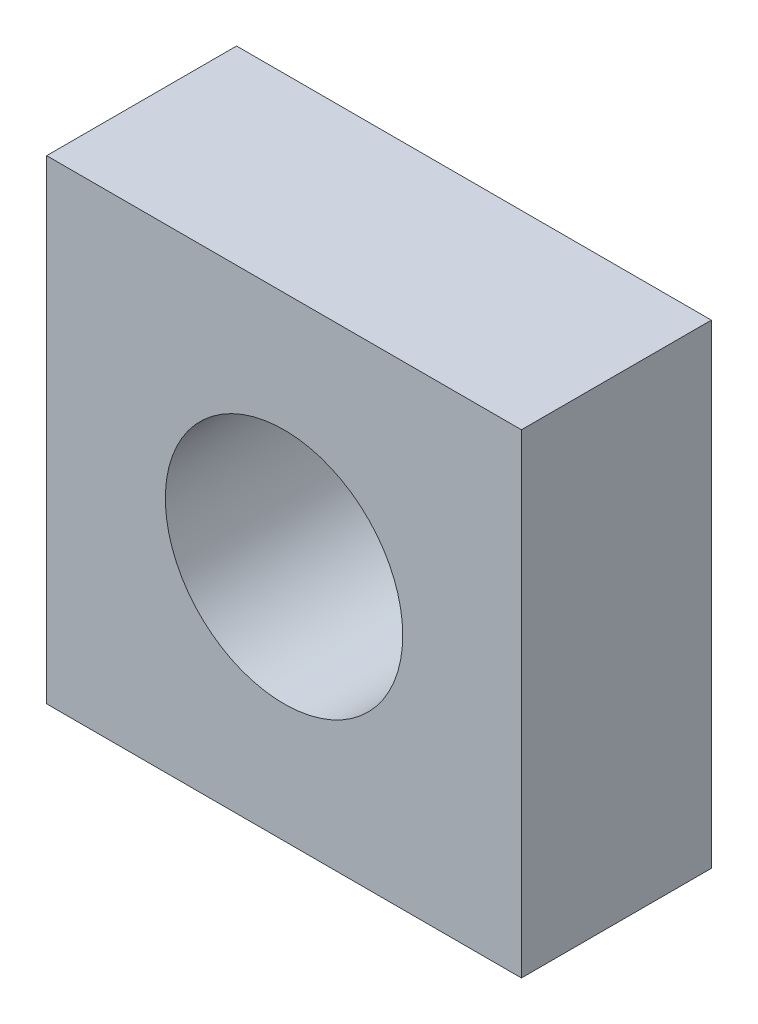
from build123d import *

# Parameters (mm, degrees)
SKETCH2_W           = 10
SKETCH2_H           = 10
BOSS_EXTRUDE1_DEPTH = 4
SKETCH3_R           = 2.5
CUT_EXTRUDE1_DEPTH  = 5


with BuildPart() as part:
    # Sketch2 → Boss-Extrude1 (new body)
    with BuildSketch(Plane.XY):
        Rectangle(SKETCH2_W, SKETCH2_H)
    extrude(amount=BOSS_EXTRUDE1_DEPTH)

    # Sketch3 → Cut-Extrude1 (cut, through all)
    with BuildSketch(Plane.XY.offset(4)):
        Circle(SKETCH3_R)
    extrude(amount=-CUT_EXTRUDE1_DEPTH, mode=Mode.SUBTRACT)


solid = part.part
